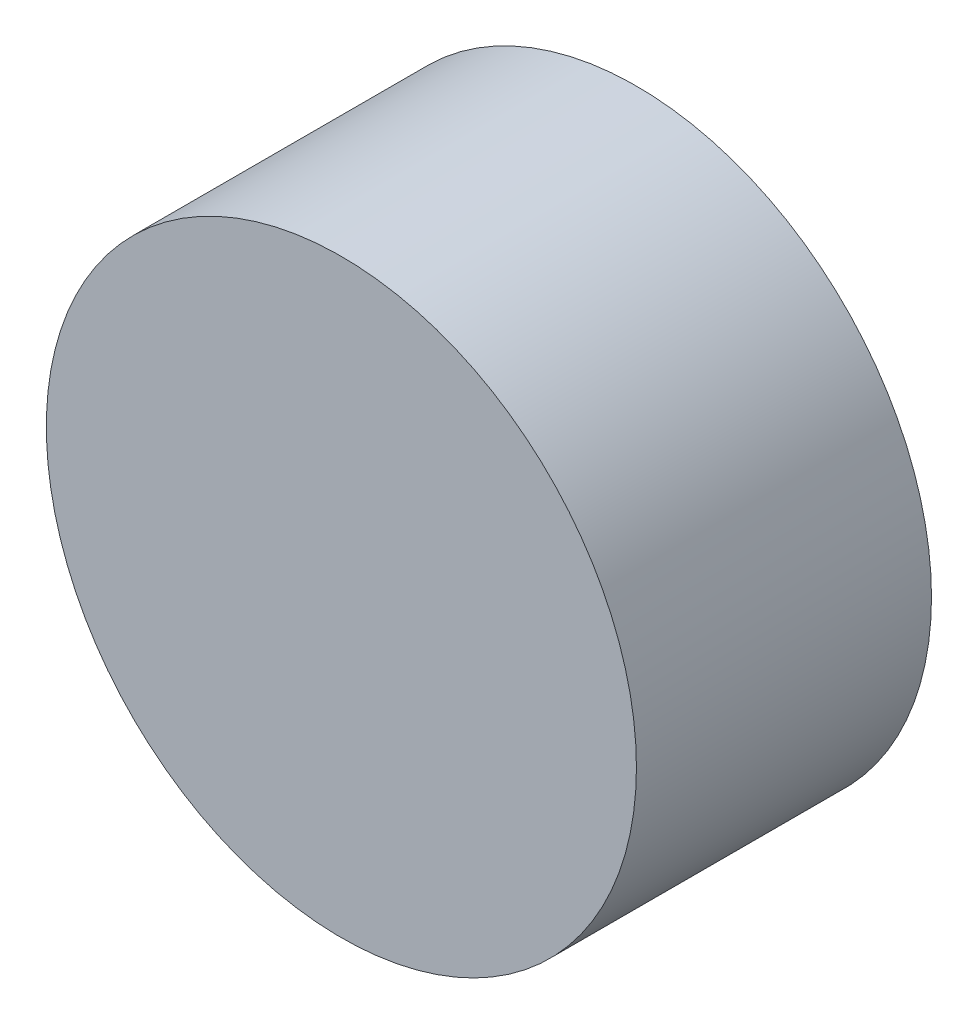
from build123d import *

# Parameters (mm, degrees)
SKETCH1_R           = 8.89
BOSS_EXTRUDE1_DEPTH = 8.89


with BuildPart() as part:
    # Sketch1 → Boss-Extrude1 (new body)
    with BuildSketch(Plane.XY):
        Circle(SKETCH1_R)
    extrude(amount=BOSS_EXTRUDE1_DEPTH)


solid = part.part
